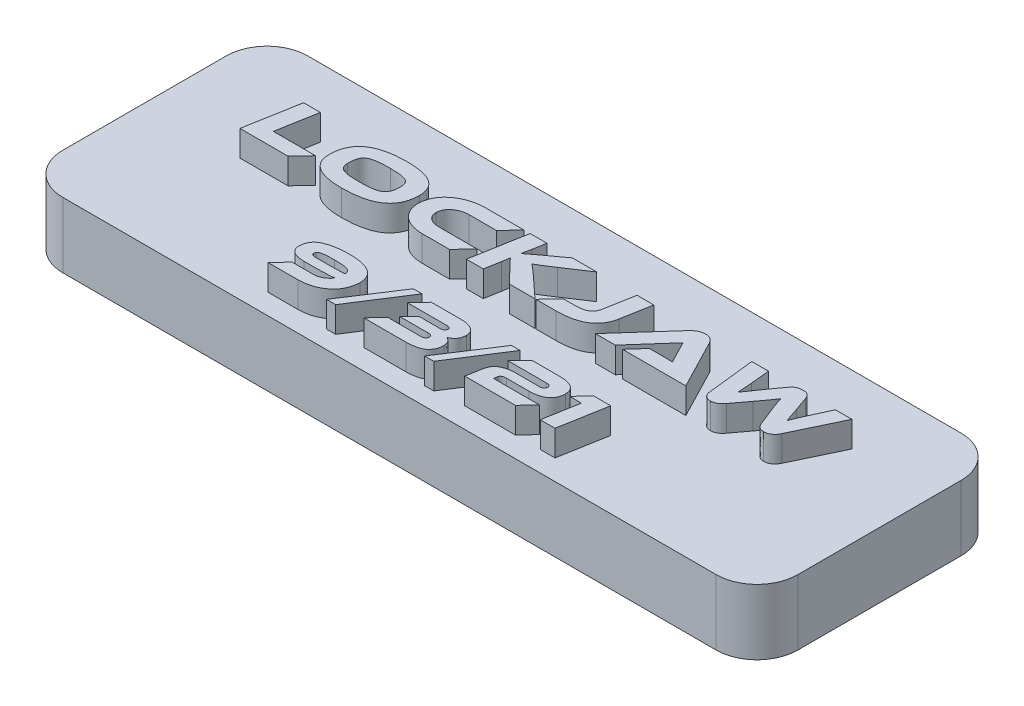
from build123d import *

# Parameters (mm, degrees)
SKETCH1_W           = 57.15
SKETCH1_H           = 19.05
BOSS_EXTRUDE1_DEPTH = 5.08
FILLET1_R           = 3.175
BOSS_EXTRUDE2_DEPTH = 2
SKETCH4_R           = 0.9
CUT_EXTRUDE1_DEPTH  = 4


with BuildPart() as part:
    # Sketch1 → Boss-Extrude1 (new body)
    with BuildSketch(Plane(origin=(0, 0, 0), x_dir=(1, 0, 0), z_dir=(0, 1, 0))):
        Rectangle(SKETCH1_W, SKETCH1_H)
    extrude(amount=BOSS_EXTRUDE1_DEPTH)

    # Fillet1
    fillet1_edges = [part.edges().sort_by_distance(p)[0] for p in [
        (-28.575, 2.54, -9.525),
        (-28.575, 2.54, 9.525),
        (28.575, 2.54, 9.525),
        (28.575, 2.54, -9.525),
    ]]
    fillet(fillet1_edges, radius=FILLET1_R)

    # Sketch3 → Boss-Extrude2 (add)
    with BuildSketch(Plane(origin=(0, 5.08, 0), x_dir=(1, 0, 0), z_dir=(0, 1, 0))):
        with BuildLine():
            add(Edge.make_bspline(
                [(18.986183794, 0.390294017), (18.99976212, 0.35659834), (19.026100294, 0.291238101), (19.081525435, 0.203566754), (19.144631038, 0.126795663), (19.217773301, 0.061464517), (19.30260435, 0.009173736), (19.399602745, -0.027898063), (19.508194542, -0.051220813), (19.584417945, -0.054206736), (19.62415657, -0.05576343)],
                knots=[0, 0, 0, 0, 0.000108788, 0.000211018, 0.000309687, 0.000406177, 0.000503855, 0.000606899, 0.00071627, 0.000835394, 0.000835394, 0.000835394, 0.000835394], degree=3))
            add(Edge.make_bspline(
                [(19.62415657, -0.05576343), (19.666042688, -0.053966236), (19.749139081, -0.050400847), (19.871269784, -0.022923383), (19.988653086, 0.022326494), (20.10037936, 0.08621565), (20.20674783, 0.166515388), (20.301522742, 0.267832701), (20.388186358, 0.385896221), (20.434086638, 0.474938977), (20.457865556, 0.521068116)],
                knots=[0, 0, 0, 0, 0.000125572, 0.000249119, 0.000373558, 0.000501686, 0.000634062, 0.000771784, 0.00091642, 0.001071894, 0.001071894, 0.001071894, 0.001071894], degree=3))
            Line((20.457865556, 0.521068116), (22.215058149, 4.208766837))
            Line((22.215058149, 4.208766837), (20.932354638, 4.208766837))
            Line((20.932354638, 4.208766837), (20.268887305, 2.747677306))
            add(Edge.make_bspline(
                [(20.268887305, 2.747677306), (20.24284878, 2.691115035), (20.192344313, 2.581406544), (20.119498413, 2.420840366), (20.053179861, 2.268156898), (19.971403478, 2.07900874), (19.879286813, 1.855843352), (19.813790966, 1.678584599), (19.782305314, 1.593371449)],
                knots=[0, 0, 0, 0, 0.000186804, 0.000362327, 0.000528939, 0.000686184, 0.000980548, 0.001253061, 0.001253061, 0.001253061, 0.001253061], degree=3))
            add(Edge.make_bspline(
                [(19.782305314, 1.593371449), (19.77106738, 1.628730463), (19.747891651, 1.701650532), (19.711147131, 1.814745435), (19.671022032, 1.934737749), (19.627147599, 2.064550408), (19.577960058, 2.208029207), (19.522457109, 2.370032374), (19.45795327, 2.551557477), (19.41350808, 2.679660987), (19.390132995, 2.747034541)],
                knots=[0, 0, 0, 0, 0.000111306, 0.000229543, 0.000356739, 0.000490873, 0.000640622, 0.000811767, 0.00100461, 0.001218549, 0.001218549, 0.001218549, 0.001218549], degree=3))
            Line((19.390132995, 2.747034541), (19.01145874, 3.807245859))
            add(Edge.make_bspline(
                [(19.01145874, 3.807245859), (18.99347067, 3.852325965), (18.959876, 3.936517944), (18.896242117, 4.046626496), (18.825696515, 4.131947336), (18.745285461, 4.191878475), (18.656078217, 4.228544866), (18.559991386, 4.254757927), (18.453739911, 4.266889771), (18.380011487, 4.266541121), (18.341597681, 4.266359469)],
                knots=[0, 0, 0, 0, 0.000145468, 0.000271678, 0.000379954, 0.000475395, 0.000569144, 0.000667601, 0.000773505, 0.000888703, 0.000888703, 0.000888703, 0.000888703], degree=3))
            add(Edge.make_bspline(
                [(18.341597681, 4.266359469), (18.303778881, 4.266605936), (18.229686331, 4.267088801), (18.120886524, 4.253253143), (18.017473425, 4.226354204), (17.916446796, 4.186729166), (17.816869629, 4.125803537), (17.716713312, 4.040430135), (17.613575981, 3.929748136), (17.548242574, 3.844050056), (17.513373623, 3.798312319)],
                knots=[0, 0, 0, 0, 0.00011337, 0.000222108, 0.00032787, 0.000433288, 0.00054648, 0.000676284, 0.000826964, 0.00099943, 0.00099943, 0.00099943, 0.00099943], degree=3))
            Line((17.513373623, 3.798312319), (16.755669807, 2.74754786))
            add(Edge.make_bspline(
                [(16.755669807, 2.74754786), (16.708968789, 2.683107943), (16.61984231, 2.560127693), (16.492980577, 2.383892073), (16.381917125, 2.222545512), (16.281756483, 2.076931266), (16.192605448, 1.942454559), (16.108851361, 1.818403356), (16.032477005, 1.701218964), (15.98309682, 1.625964326), (15.959310821, 1.589714831)],
                knots=[0, 0, 0, 0, 0.000238752, 0.000455645, 0.000651411, 0.000826366, 0.000985844, 0.001135433, 0.001275391, 0.001405461, 0.001405461, 0.001405461, 0.001405461], degree=3))
            add(Edge.make_bspline(
                [(15.959310821, 1.589714831), (15.95550415, 1.675368182), (15.947696002, 1.851058184), (15.930400577, 2.073939086), (15.916447035, 2.261979973), (15.90303314, 2.413326184), (15.890587585, 2.573966159), (15.88164471, 2.68396087), (15.877036908, 2.740635459)],
                knots=[0, 0, 0, 0, 0.000257196, 0.000527554, 0.000670584, 0.000822872, 0.00098336, 0.001153945, 0.001153945, 0.001153945, 0.001153945], degree=3))
            Line((15.877036908, 2.740635459), (15.738353229, 4.208766837))
            Line((15.738353229, 4.208766837), (14.436693509, 4.208766837))
            Line((14.436693509, 4.208766837), (14.847411382, 0.521956381))
            add(Edge.make_bspline(
                [(14.847411382, 0.521956381), (14.854071548, 0.475879894), (14.866689218, 0.388588094), (14.91073672, 0.268486973), (14.972052988, 0.166864567), (15.051783753, 0.085127629), (15.143963695, 0.021611916), (15.246993521, -0.023547257), (15.359757829, -0.05075639), (15.438087826, -0.054060316), (15.478465507, -0.05576343)],
                knots=[0, 0, 0, 0, 0.000139353, 0.000264003, 0.000380965, 0.00049281, 0.000603875, 0.000714793, 0.000828538, 0.000949553, 0.000949553, 0.000949553, 0.000949553], degree=3))
            add(Edge.make_bspline(
                [(15.478465507, -0.05576343), (15.520037297, -0.054227117), (15.601447354, -0.051218556), (15.719044365, -0.026371075), (15.829645495, 0.011033214), (15.932430796, 0.064036572), (16.028628054, 0.129041502), (16.117352912, 0.206145636), (16.201706875, 0.291606614), (16.250134159, 0.356512635), (16.274694155, 0.389429855)],
                knots=[0, 0, 0, 0, 0.000124597, 0.000243998, 0.000359058, 0.00047394, 0.000589811, 0.000706515, 0.000826116, 0.000949188, 0.000949188, 0.000949188, 0.000949188], degree=3))
            Line((16.274694155, 0.389429855), (17.16638768, 1.581524934))
            add(Edge.make_bspline(
                [(17.16638768, 1.581524934), (17.195195094, 1.619914287), (17.251436502, 1.694862747), (17.333594252, 1.80400567), (17.410456884, 1.908009798), (17.483464099, 2.005158237), (17.551176421, 2.096529307), (17.613371695, 2.182272838), (17.672133556, 2.261174582), (17.741210345, 2.35836954), (17.82141431, 2.471255316), (17.909884689, 2.599796099), (17.989842835, 2.719803389), (18.039145575, 2.797531669), (18.062780531, 2.834793382)],
                knots=[0, 0, 0, 0, 0.000143988, 0.000281111, 0.000409825, 0.000531956, 0.00064568, 0.000750998, 0.000849731, 0.000940803, 0.001108709, 0.00126516, 0.001408918, 0.001541291, 0.001541291, 0.001541291, 0.001541291], degree=3))
            add(Edge.make_bspline(
                [(18.062780531, 2.834793382), (18.073922071, 2.797272073), (18.097079181, 2.719285985), (18.135900901, 2.598434094), (18.178529085, 2.468702978), (18.22791939, 2.328207331), (18.28627708, 2.171969979), (18.352168693, 1.993762327), (18.431694754, 1.792495165), (18.488144655, 1.650343935), (18.518029517, 1.575088357)],
                knots=[0, 0, 0, 0, 0.000117418, 0.000244048, 0.000380783, 0.000527076, 0.000690779, 0.000881121, 0.001097055, 0.001339974, 0.001339974, 0.001339974, 0.001339974], degree=3))
            Line((18.518029517, 1.575088357), (18.986183794, 0.390294017))
        make_face()
        with BuildLine():
            Line((13.508655197, 0.006075914), (11.543528143, 3.800574494))
            add(Edge.make_bspline(
                [(11.543528143, 3.800574494), (11.525407199, 3.832806008), (11.489448535, 3.896765269), (11.424574846, 3.985575321), (11.347315359, 4.0630874), (11.262412447, 4.133983071), (11.164606553, 4.192399523), (11.052495404, 4.23493807), (10.926453576, 4.260058315), (10.837722643, 4.264204191), (10.791594928, 4.266359469)],
                knots=[0, 0, 0, 0, 0.000110886, 0.000220038, 0.000328642, 0.000438436, 0.000551159, 0.000668641, 0.000796469, 0.000934872, 0.000934872, 0.000934872, 0.000934872], degree=3))
            add(Edge.make_bspline(
                [(10.791594928, 4.266359469), (10.741783268, 4.264009128), (10.645052147, 4.259444915), (10.505013391, 4.230967468), (10.374734829, 4.187726952), (10.254999954, 4.126959855), (10.145318298, 4.055096369), (10.042116945, 3.977511138), (9.947810732, 3.892229282), (9.890428229, 3.830720556), (9.86189971, 3.800140628)],
                knots=[0, 0, 0, 0, 0.00014941, 0.000290146, 0.000427171, 0.000560039, 0.000691642, 0.000820174, 0.000947034, 0.001072464, 0.001072464, 0.001072464, 0.001072464], degree=3))
            Line((9.86189971, 3.800140628), (6.475901464, 0.006075914))
            Line((6.475901464, 0.006075914), (8.023991908, 0.006075914))
            Line((8.023991908, 0.006075914), (10.500936619, 2.798493231))
            Line((10.500936619, 2.798493231), (11.063304168, 1.696826253))
            add(Edge.make_bspline(
                [(11.063304168, 1.696826253), (11.089978173, 1.644325557), (11.14449442, 1.5370248), (11.213922761, 1.403208105), (11.270005855, 1.297464771), (11.31114697, 1.223921613), (11.347550811, 1.155498073), (11.372849117, 1.112747401), (11.384881256, 1.092414734)],
                knots=[0, 0, 0, 0, 0.000176664, 0.000361065, 0.000452265, 0.000535729, 0.000613867, 0.000684736, 0.000684736, 0.000684736, 0.000684736], degree=3))
            add(Edge.make_bspline(
                [(11.384881256, 1.092414734), (11.329432911, 1.095166522), (11.211273076, 1.101030553), (11.026842541, 1.103502684), (10.831823675, 1.10564963), (10.699571078, 1.105358474), (10.633446184, 1.105212899)],
                knots=[0, 0, 0, 0, 0.000166537, 0.000354888, 0.000553268, 0.00075164, 0.00075164, 0.00075164, 0.00075164], degree=3))
            Line((10.633446184, 1.105212899), (9.578401089, 1.105536066))
            Line((9.578401089, 1.105536066), (8.592678194, 0.006075914))
            Line((8.592678194, 0.006075914), (13.508655197, 0.006075914))
        make_face()
        with BuildLine():
            Line((2.896527384, 1.105536066), (1.85393586, 0.006075914))
            Line((1.85393586, 0.006075914), (3.433619987, 0.006075914))
            add(Edge.make_bspline(
                [(3.433619987, 0.006075914), (3.540603796, 0.007436861), (3.748751622, 0.01008472), (4.05203722, 0.033601879), (4.337633993, 0.070034612), (4.605136925, 0.123100908), (4.855045242, 0.190249301), (5.086842949, 0.273347313), (5.300890406, 0.371079513), (5.497144423, 0.48385062), (5.675213459, 0.612113229), (5.83541056, 0.755344205), (5.977226893, 0.913926316), (6.101380797, 1.087099416), (6.205659916, 1.276680487), (6.293868991, 1.479889032), (6.362748449, 1.698830152), (6.393462514, 1.851135315), (6.409137826, 1.928866184)],
                knots=[0, 0, 0, 0, 0.000320904, 0.000624351, 0.000912019, 0.001184167, 0.001441855, 0.001687642, 0.001922026, 0.002146874, 0.002365577, 0.002579208, 0.002790257, 0.003002581, 0.00321701, 0.003438115, 0.003666231, 0.003904002, 0.003904002, 0.003904002, 0.003904002], degree=3))
            Line((6.409137826, 1.928866184), (6.820462755, 4.208766837))
            Line((6.820462755, 4.208766837), (5.512484298, 4.208766837))
            Line((5.512484298, 4.208766837), (5.101766425, 1.929710705))
            add(Edge.make_bspline(
                [(5.101766425, 1.929710705), (5.095231607, 1.893606074), (5.082511058, 1.823325499), (5.051709765, 1.723454142), (5.014601284, 1.631221767), (4.968489875, 1.54698296), (4.913508536, 1.470828714), (4.850009523, 1.402917424), (4.778646621, 1.342591695), (4.698246485, 1.290059858), (4.606663952, 1.244899766), (4.503587515, 1.205769862), (4.387346694, 1.174394554), (4.259095052, 1.148174238), (4.118189231, 1.126841942), (3.964272012, 1.114206072), (3.797806436, 1.105451756), (3.682532606, 1.105294429), (3.622794638, 1.105212899)],
                knots=[0, 0, 0, 0, 0.000109985, 0.000214094, 0.000312895, 0.000407813, 0.000501437, 0.000593929, 0.000686046, 0.000781127, 0.000881288, 0.000991814, 0.001111359, 0.001242057, 0.001384398, 0.001538587, 0.001705167, 0.00188435, 0.00188435, 0.00188435, 0.00188435], degree=3))
            Line((3.622794638, 1.105212899), (2.896527384, 1.105536066))
        make_face()
        with BuildLine():
            add(Edge.make_bspline(
                [(0.278086897, 1.392796648), (0.222599014, 1.444148917), (0.116774505, 1.542086129), (-0.034532052, 1.681114661), (-0.171553727, 1.803755219), (-0.295233828, 1.91073157), (-0.406659478, 2.004665505), (-0.507553369, 2.087751254), (-0.59768524, 2.162340495), (-0.655654047, 2.207502793), (-0.682873478, 2.228708889)],
                knots=[0, 0, 0, 0, 0.000226812, 0.000432568, 0.000616438, 0.000778458, 0.000923128, 0.001053635, 0.001170568, 0.001274078, 0.001274078, 0.001274078, 0.001274078], degree=3))
            add(Edge.make_bspline(
                [(-0.682873478, 2.228708889), (-0.646174216, 2.248893261), (-0.5697249, 2.290939924), (-0.453204862, 2.361216069), (-0.327684242, 2.436928321), (-0.21763428, 2.505144405), (-0.124036604, 2.56592842), (-0.045394079, 2.614596148), (0.038665443, 2.668609755), (0.128233465, 2.727779939), (0.225207431, 2.789191838), (0.32764198, 2.856322237), (0.436213093, 2.927646986), (0.510990092, 2.976216726), (0.549406908, 3.001169517)],
                knots=[0, 0, 0, 0, 0.000125639, 0.000261722, 0.000408152, 0.000565422, 0.000650118, 0.000742948, 0.000842859, 0.000949858, 0.001064984, 0.001187197, 0.001317267, 0.001454695, 0.001454695, 0.001454695, 0.001454695], degree=3))
            Line((0.549406908, 3.001169517), (2.375907418, 4.208766837))
            Line((2.375907418, 4.208766837), (0.480286466, 4.208766837))
            Line((0.480286466, 4.208766837), (-0.922473039, 3.184222724))
            add(Edge.make_bspline(
                [(-0.922473039, 3.184222724), (-0.974583562, 3.145800749), (-1.074176155, 3.072369434), (-1.216449838, 2.966341556), (-1.343932519, 2.868077071), (-1.459874757, 2.78030253), (-1.563914934, 2.699934929), (-1.658107517, 2.627231809), (-1.742017243, 2.56017035), (-1.795080218, 2.518172521), (-1.820081787, 2.498384493)],
                knots=[0, 0, 0, 0, 0.000194232, 0.000371213, 0.000532293, 0.000677099, 0.000807468, 0.000926691, 0.001034053, 0.001129707, 0.001129707, 0.001129707, 0.001129707], degree=3))
            add(Edge.make_bspline(
                [(-1.820081787, 2.498384493), (-1.807635142, 2.556291112), (-1.782276644, 2.674268681), (-1.7426007, 2.854516053), (-1.702453237, 3.041935514), (-1.675607969, 3.169366069), (-1.661933043, 3.234278937)],
                knots=[0, 0, 0, 0, 0.000177687, 0.000362016, 0.000553686, 0.000752698, 0.000752698, 0.000752698, 0.000752698], degree=3))
            Line((-1.661933043, 3.234278937), (-1.491159325, 4.208766837))
            Line((-1.491159325, 4.208766837), (-2.799137782, 4.208766837))
            Line((-2.799137782, 4.208766837), (-3.551067426, 0.003655726))
            Line((-3.551067426, 0.003655726), (-2.236770233, 0.003655726))
            Line((-2.236770233, 0.003655726), (-2.021933191, 1.210511188))
            Line((-2.021933191, 1.210511188), (-1.93347088, 1.813938919))
            add(Edge.make_bspline(
                [(-1.93347088, 1.813938919), (-1.918965118, 1.795462482), (-1.887374276, 1.755224254), (-1.833571925, 1.693009619), (-1.770827678, 1.62316502), (-1.698953792, 1.544515914), (-1.614145014, 1.455892519), (-1.516383703, 1.352868269), (-1.401953851, 1.236299033), (-1.320365048, 1.153641713), (-1.277073961, 1.109783671)],
                knots=[0, 0, 0, 0, 7.0463e-05, 0.000153455, 0.000246681, 0.000352142, 0.000473063, 0.000614662, 0.000778214, 0.00096309, 0.00096309, 0.00096309, 0.00096309], degree=3))
            Line((-1.277073961, 1.109783671), (-0.195818341, 0.003655726))
            Line((-0.195818341, 0.003655726), (1.781946186, 0.003655726))
            Line((1.781946186, 0.003655726), (0.278086897, 1.392796648))
        make_face()
        with BuildLine():
            add(Edge.make_bspline(
                [(-6.798337357, 1.105536066), (-6.838058387, 1.106368572), (-6.915473869, 1.107991107), (-7.028300956, 1.120099472), (-7.134545949, 1.139341634), (-7.234957539, 1.164731953), (-7.329490449, 1.197730851), (-7.418000542, 1.237674392), (-7.500298132, 1.284870974), (-7.576103435, 1.338214411), (-7.643574673, 1.398892985), (-7.703559843, 1.463686553), (-7.754317503, 1.534061863), (-7.796801284, 1.609307897), (-7.829638278, 1.690172386), (-7.853450091, 1.775740301), (-7.868223712, 1.866215268), (-7.871183518, 1.928202108), (-7.872699324, 1.95994744)],
                knots=[0, 0, 0, 0, 0.000119146, 0.000232213, 0.000339979, 0.000442857, 0.0005426, 0.00063997, 0.000733741, 0.000826832, 0.000917476, 0.001005473, 0.001091233, 0.001177183, 0.0012641, 0.001352376, 0.001443149, 0.001538437, 0.001538437, 0.001538437, 0.001538437], degree=3))
            add(Edge.make_bspline(
                [(-7.872699324, 1.95994744), (-7.870321703, 2.00089212), (-7.865637766, 2.08155355), (-7.841878414, 2.199187811), (-7.807397548, 2.311187764), (-7.760421106, 2.41754111), (-7.700292506, 2.517456178), (-7.628868238, 2.612420697), (-7.543697211, 2.700160835), (-7.448337067, 2.782047564), (-7.343309937, 2.855559397), (-7.231827439, 2.920673089), (-7.113914533, 2.975739929), (-6.990303772, 3.021270473), (-6.860843125, 3.058247704), (-6.72533952, 3.084423964), (-6.583831529, 3.10108536), (-6.487495527, 3.104537604), (-6.438390773, 3.106297295)],
                knots=[0, 0, 0, 0, 0.000122909, 0.000242131, 0.000358943, 0.000473945, 0.00058996, 0.00070807, 0.000829622, 0.000956043, 0.00108463, 0.001213669, 0.001342898, 0.001474501, 0.001608483, 0.001746351, 0.001888089, 0.00203545, 0.00203545, 0.00203545, 0.00203545], degree=3))
            Line((-6.438390773, 3.106297295), (-4.31507391, 3.106887389))
            Line((-4.31507391, 3.106887389), (-3.278801122, 4.206347541))
            Line((-3.278801122, 4.206347541), (-6.242288544, 4.206347541))
            add(Edge.make_bspline(
                [(-6.242288544, 4.206347541), (-6.344308335, 4.202700375), (-6.54411621, 4.195557324), (-6.837332125, 4.162353327), (-7.117469231, 4.110015155), (-7.384330179, 4.036172143), (-7.638938939, 3.945267581), (-7.88006559, 3.833094278), (-8.10870688, 3.702119343), (-8.287619412, 3.576781715), (-8.423153353, 3.469194079), (-8.517230977, 3.383435035), (-8.606060518, 3.295964452), (-8.688859654, 3.205335074), (-8.764362551, 3.110727377), (-8.835548333, 3.01426649), (-8.898086777, 2.913020304), (-8.95625324, 2.809716549), (-9.007448564, 2.702914965), (-9.051291828, 2.592415367), (-9.089450236, 2.479140843), (-9.122993341, 2.363167205), (-9.147953385, 2.243547853), (-9.168651558, 2.121372678), (-9.181086219, 1.99550854), (-9.185180632, 1.910604524), (-9.187253623, 1.867617826)],
                knots=[0, 0, 0, 0, 0.000306166, 0.000599632, 0.000884344, 0.001160233, 0.001429449, 0.00169448, 0.001956971, 0.002218938, 0.002348999, 0.002475859, 0.002600617, 0.002722926, 0.00284385, 0.002963619, 0.003082322, 0.003200591, 0.003319167, 0.003437316, 0.003556997, 0.003677669, 0.003799234, 0.003923371, 0.004049262, 0.004178365, 0.004178365, 0.004178365, 0.004178365], degree=3))
            add(Edge.make_bspline(
                [(-9.187253623, 1.867617826), (-9.18425375, 1.801688472), (-9.17834879, 1.671912941), (-9.147898283, 1.482185543), (-9.099245168, 1.301387781), (-9.032438889, 1.130003576), (-8.947430611, 0.967607666), (-8.844896562, 0.814264123), (-8.722644306, 0.671011828), (-8.584413038, 0.536982875), (-8.430156534, 0.415938203), (-8.262597142, 0.308972587), (-8.081891269, 0.218224767), (-7.887661366, 0.144692398), (-7.681491487, 0.084618858), (-7.461656587, 0.042789332), (-7.229588352, 0.013380635), (-7.070165101, 0.00815489), (-6.988711836, 0.005484928)],
                knots=[0, 0, 0, 0, 0.000197872, 0.000389491, 0.000575101, 0.000758611, 0.000940158, 0.001123976, 0.001310786, 0.001504088, 0.001700684, 0.001897981, 0.00209953, 0.002306142, 0.002520237, 0.002742905, 0.002976823, 0.003221191, 0.003221191, 0.003221191, 0.003221191], degree=3))
            Line((-6.988711836, 0.005484928), (-4.864803986, 0.006075914))
            Line((-4.864803986, 0.006075914), (-3.834849935, 1.105536066))
            Line((-3.834849935, 1.105536066), (-6.798337357, 1.105536066))
        make_face()
        with BuildLine():
            add(Edge.make_bspline(
                [(-12.41441751, 4.264853435), (-12.487490224, 4.264150041), (-12.630994334, 4.262768679), (-12.842455965, 4.255304453), (-13.046731704, 4.243828802), (-13.243925852, 4.226275073), (-13.434153165, 4.204448808), (-13.61745774, 4.178135377), (-13.79375449, 4.146346882), (-13.962891887, 4.108703546), (-14.124867986, 4.066841285), (-14.27973055, 4.020018599), (-14.42794031, 3.969271115), (-14.569199404, 3.912462076), (-14.703093624, 3.850145336), (-14.830863089, 3.784672178), (-14.950912353, 3.713307743), (-15.063401162, 3.636054084), (-15.169926994, 3.555015487), (-15.268647714, 3.467997248), (-15.360501229, 3.375795294), (-15.44657254, 3.27972572), (-15.524313638, 3.176938462), (-15.596998879, 3.070861845), (-15.660439651, 2.958180712), (-15.719968361, 2.842029764), (-15.770661171, 2.71956376), (-15.814379021, 2.592115874), (-15.852316279, 2.460138961), (-15.881981709, 2.322911611), (-15.905857087, 2.180763117), (-15.923186622, 2.033740252), (-15.93351106, 1.881481624), (-15.934251986, 1.778351657), (-15.934628647, 1.725923865)],
                knots=[0, 0, 0, 0, 0.00021922, 0.000430517, 0.000634719, 0.000832939, 0.001024345, 0.001209088, 0.001388397, 0.001561619, 0.0017288, 0.001890173, 0.002046865, 0.002198625, 0.002346687, 0.00248979, 0.002629165, 0.002765325, 0.002898982, 0.003030471, 0.003159752, 0.003289265, 0.003417071, 0.003546125, 0.003674706, 0.003804712, 0.003937476, 0.004071906, 0.004208776, 0.004349179, 0.004492852, 0.004641052, 0.004793135, 0.004950393, 0.004950393, 0.004950393, 0.004950393], degree=3))
            add(Edge.make_bspline(
                [(-15.934628647, 1.725923865), (-15.932700206, 1.652651179), (-15.928958987, 1.510500548), (-15.894920117, 1.304743113), (-15.841731264, 1.113533359), (-15.766034338, 0.936607339), (-15.668481681, 0.774301847), (-15.548646873, 0.627005612), (-15.40668961, 0.495143384), (-15.243800024, 0.377875494), (-15.059361854, 0.275513814), (-14.853937578, 0.187096535), (-14.627753067, 0.111278664), (-14.379925278, 0.05083109), (-14.111479636, 0.003624777), (-13.821794326, -0.029580863), (-13.510887823, -0.049844784), (-13.296410855, -0.051940053), (-13.185765797, -0.053020966)],
                knots=[0, 0, 0, 0, 0.000219671, 0.000426167, 0.000623813, 0.000813827, 0.001001645, 0.001190103, 0.001381548, 0.00158123, 0.001790776, 0.002013083, 0.002251287, 0.002505594, 0.002777627, 0.003068474, 0.003379936, 0.003711836, 0.003711836, 0.003711836, 0.003711836], degree=3))
            add(Edge.make_bspline(
                [(-13.185765797, -0.053020966), (-13.112931131, -0.052455169), (-12.969663125, -0.051342229), (-12.758142511, -0.043724787), (-12.553852623, -0.032438481), (-12.356685132, -0.014624257), (-12.166363266, 0.006825126), (-11.983191514, 0.034388638), (-11.80685628, 0.066140884), (-11.637990359, 0.103671999), (-11.475809626, 0.145843098), (-11.320298149, 0.191939017), (-11.172255094, 0.24436261), (-11.030979389, 0.30061376), (-10.89739621, 0.363320067), (-10.769984413, 0.429548791), (-10.65023399, 0.501958418), (-10.537455839, 0.579052293), (-10.431025722, 0.660209293), (-10.331920641, 0.747143393), (-10.240711826, 0.84029394), (-10.154284341, 0.93631177), (-10.07658864, 1.03914999), (-10.003931378, 1.145233071), (-9.940198719, 1.258074334), (-9.88117739, 1.374784654), (-9.830200043, 1.497412041), (-9.786527699, 1.624884051), (-9.748592492, 1.756856749), (-9.718806446, 1.894369804), (-9.695138033, 2.036857562), (-9.677695851, 2.184166254), (-9.66739263, 2.336428379), (-9.666648778, 2.439557863), (-9.666270628, 2.491985411)],
                knots=[0, 0, 0, 0, 0.0002185, 0.000429796, 0.000634912, 0.000832221, 0.001023627, 0.001209407, 0.001387817, 0.001561039, 0.001728219, 0.001890468, 0.002047461, 0.002199222, 0.002346454, 0.00248998, 0.002629824, 0.002765984, 0.002899642, 0.003031131, 0.00316106, 0.003290573, 0.003418378, 0.003547433, 0.003676014, 0.003806837, 0.003939601, 0.004074031, 0.004210901, 0.004351303, 0.004495879, 0.004644079, 0.004796161, 0.00495342, 0.00495342, 0.00495342, 0.00495342], degree=3))
            add(Edge.make_bspline(
                [(-9.666270628, 2.491985411), (-9.66835156, 2.564930001), (-9.672404001, 2.706983534), (-9.704535356, 2.912703512), (-9.758532642, 3.104122883), (-9.834521662, 3.280748696), (-9.932475124, 3.44245971), (-10.051614119, 3.589369287), (-10.193023354, 3.721034434), (-10.356535287, 3.837071522), (-10.540568068, 3.940135668), (-10.746610644, 4.0266221), (-10.97247745, 4.102333874), (-11.220495436, 4.161421518), (-11.489113944, 4.208718585), (-11.779070302, 4.242297194), (-12.090050904, 4.261022072), (-12.304495302, 4.263336881), (-12.41441751, 4.264853435)],
                knots=[0, 0, 0, 0, 0.000218758, 0.000426013, 0.00062278, 0.000813995, 0.001001031, 0.001188203, 0.001379648, 0.001578795, 0.001788342, 0.002011126, 0.002248172, 0.002502261, 0.002775194, 0.003066041, 0.003377445, 0.003709345, 0.003709345, 0.003709345, 0.003709345], degree=3))
        make_face()
        with BuildLine():
            add(Edge.make_bspline(
                [(-12.995741268, 1.047030173), (-13.064261906, 1.04660261), (-13.19618116, 1.045779446), (-13.387040983, 1.049733712), (-13.563205392, 1.061186797), (-13.725309044, 1.075736974), (-13.872977067, 1.097737934), (-14.006303785, 1.125013299), (-14.126143516, 1.156348623), (-14.232009125, 1.194530349), (-14.325857822, 1.240026498), (-14.405753206, 1.297252332), (-14.47435919, 1.363776891), (-14.528262177, 1.441900597), (-14.571132127, 1.529303822), (-14.600956837, 1.627061382), (-14.618541942, 1.735031597), (-14.619550508, 1.81026116), (-14.620074348, 1.849334734)],
                knots=[0, 0, 0, 0, 0.000205565, 0.000395764, 0.000572537, 0.000735087, 0.000883892, 0.001020147, 0.001143219, 0.001255139, 0.001357344, 0.001455005, 0.001548736, 0.001642574, 0.001738242, 0.001839729, 0.001948086, 0.002065187, 0.002065187, 0.002065187, 0.002065187], degree=3))
            add(Edge.make_bspline(
                [(-14.620074348, 1.849334734), (-14.621722868, 1.911811071), (-14.624878718, 2.031412847), (-14.612980933, 2.203375738), (-14.588019919, 2.359667266), (-14.54917124, 2.50079582), (-14.495905949, 2.626166729), (-14.430341334, 2.737052728), (-14.348529186, 2.83042282), (-14.269323106, 2.895436203), (-14.198672358, 2.940784123), (-14.138175275, 2.971515459), (-14.071084751, 2.999666566), (-13.997819894, 3.026084681), (-13.918302258, 3.05083148), (-13.832245461, 3.072755525), (-13.739305359, 3.09131218), (-13.64021296, 3.110411596), (-13.533879375, 3.124111193), (-13.421497178, 3.137374608), (-13.302246165, 3.147018552), (-13.17668481, 3.155167115), (-13.044435416, 3.161792983), (-12.905751266, 3.165320712), (-12.76037763, 3.166041701), (-12.661345225, 3.165221911), (-12.61076256, 3.164803188)],
                knots=[0, 0, 0, 0, 0.000187411, 0.00035877, 0.00051627, 0.000661555, 0.000796714, 0.00092386, 0.001046319, 0.001167112, 0.001230003, 0.001297872, 0.001370374, 0.001448163, 0.001531436, 0.001620123, 0.001714428, 0.001815734, 0.00192278, 0.002035947, 0.002155212, 0.002281633, 0.002413427, 0.002552426, 0.00269778, 0.002849532, 0.002849532, 0.002849532, 0.002849532], degree=3))
            add(Edge.make_bspline(
                [(-12.61076256, 3.164803188), (-12.54189731, 3.165086646), (-12.408719464, 3.165634822), (-12.216296995, 3.161832074), (-12.038604406, 3.150341942), (-11.875309443, 3.135653139), (-11.726660115, 3.114010286), (-11.592525781, 3.086275793), (-11.472491776, 3.055550786), (-11.366871648, 3.01670025), (-11.27332312, 2.971781209), (-11.194078698, 2.913989507), (-11.125752645, 2.847457656), (-11.070555236, 2.770130915), (-11.028908983, 2.682069422), (-11.000152171, 2.584313015), (-10.982294275, 2.476491904), (-10.981327212, 2.401253582), (-10.980824928, 2.362175459)],
                knots=[0, 0, 0, 0, 0.000206599, 0.00039954, 0.000577225, 0.000740685, 0.000891298, 0.001027553, 0.001151508, 0.001262569, 0.001364775, 0.001461693, 0.001555424, 0.00164979, 0.00174506, 0.001846279, 0.001954636, 0.002071737, 0.002071737, 0.002071737, 0.002071737], degree=3))
            add(Edge.make_bspline(
                [(-10.980824928, 2.362175459), (-10.979202554, 2.300007823), (-10.97609742, 2.181022384), (-10.987669119, 2.009565903), (-11.013895913, 1.85401663), (-11.052829077, 1.713235889), (-11.105723704, 1.587793863), (-11.172491868, 1.477427264), (-11.254520861, 1.383606431), (-11.333987434, 1.317707612), (-11.405725841, 1.272767382), (-11.466570865, 1.241979786), (-11.533240443, 1.212524455), (-11.607025104, 1.186264377), (-11.686891096, 1.161664348), (-11.773634432, 1.139884782), (-11.866551131, 1.119635522), (-11.966388344, 1.102726509), (-12.072390278, 1.086938186), (-12.185207526, 1.074209563), (-12.304444032, 1.064550242), (-12.430305563, 1.056272217), (-12.56255975, 1.049750773), (-12.701546778, 1.046182113), (-12.846920811, 1.045470465), (-12.945953161, 1.046288949), (-12.995741268, 1.047030173)],
                knots=[0, 0, 0, 0, 0.000186496, 0.000356944, 0.000514595, 0.000659, 0.000794159, 0.000921781, 0.00104424, 0.00116632, 0.001229983, 0.001297853, 0.001370716, 0.001448505, 0.001532652, 0.001621339, 0.001716727, 0.001817873, 0.001925047, 0.002038214, 0.00215839, 0.002283899, 0.002416606, 0.002555606, 0.002700959, 0.002852711, 0.002852711, 0.002852711, 0.002852711], degree=3))
        make_face(mode=Mode.SUBTRACT)
        Polygon((-19.663800884, 1.105536066), (-19.107752071, 4.208766837), (-20.409411791, 4.208766837), (-21.161341436, 0.006075914), (-17.42696816, 0.006075914), (-16.384376636, 1.105536066), align=None)
        Polygon((9.710846154, -5.218973535), (10.612055948, -5.218973535), (10.131042132, -7.93430124), (11.275523281, -7.93430124), (11.93346172, -4.256945902), (10.578882582, -4.256945902), align=None)
        with BuildLine():
            Line((4.894237041, -5.218973535), (7.885368935, -5.218973535))
            add(Edge.make_bspline(
                [(7.885368935, -5.218973535), (7.913069849, -5.218922741), (7.964916224, -5.218827674), (8.037645227, -5.225918073), (8.099169268, -5.242216387), (8.150999805, -5.26353583), (8.191093194, -5.294908436), (8.219407194, -5.334273792), (8.236959171, -5.381008794), (8.238183871, -5.4147712), (8.238818237, -5.432259348)],
                knots=[0, 0, 0, 0, 8.3099e-05, 0.000155531, 0.000218392, 0.000273538, 0.000322508, 0.000368908, 0.000417497, 0.000469711, 0.000469711, 0.000469711, 0.000469711], degree=3))
            add(Edge.make_bspline(
                [(8.238818237, -5.432259348), (8.238178443, -5.458018948), (8.236968839, -5.506720508), (8.216406453, -5.573936821), (8.183120077, -5.630194031), (8.133906454, -5.673414306), (8.070375355, -5.704561408), (7.992641188, -5.726311626), (7.899516029, -5.738498194), (7.832514384, -5.73961472), (7.796481685, -5.740215175)],
                knots=[0, 0, 0, 0, 7.6993e-05, 0.000145564, 0.000208395, 0.000270703, 0.000339032, 0.00041902, 0.000511893, 0.000619952, 0.000619952, 0.000619952, 0.000619952], degree=3))
            Line((7.796481685, -5.740215175), (6.038718191, -5.739416071))
            add(Edge.make_bspline(
                [(6.038718191, -5.739416071), (5.983116035, -5.740560639), (5.874862873, -5.742789025), (5.716867546, -5.753609346), (5.568148187, -5.772857955), (5.428525319, -5.798779792), (5.298262121, -5.833149331), (5.177183268, -5.875619954), (5.064915888, -5.92500466), (4.961714021, -5.98174212), (4.868244824, -6.047028209), (4.783719331, -6.120143527), (4.708318722, -6.201107035), (4.6423177, -6.289606037), (4.585936126, -6.385733808), (4.538840371, -6.489539314), (4.499893008, -6.600822081), (4.482571332, -6.678800473), (4.473758291, -6.718474855)],
                knots=[0, 0, 0, 0, 0.000166829, 0.000324804, 0.000474816, 0.000616477, 0.000750546, 0.000878553, 0.001001026, 0.001118108, 0.001231277, 0.001342418, 0.001452782, 0.001562526, 0.00167296, 0.001786425, 0.001904052, 0.002025887, 0.002025887, 0.002025887, 0.002025887], degree=3))
            Line((4.473758291, -6.718474855), (4.25841418, -7.932183575))
            Line((4.25841418, -7.932183575), (8.194987024, -7.932183575))
            Line((8.194987024, -7.932183575), (9.101725713, -6.970155942))
            Line((9.101725713, -6.970155942), (5.530059902, -6.970155942))
            Line((5.530059902, -6.970155942), (5.579819952, -6.707239748))
            add(Edge.make_bspline(
                [(5.579819952, -6.707239748), (5.583597476, -6.686112106), (5.590920233, -6.645156023), (5.619631586, -6.590591717), (5.657992279, -6.543848716), (5.70933161, -6.508043577), (5.770407077, -6.47963759), (5.842724697, -6.461031101), (5.925788118, -6.450993538), (5.984711628, -6.450679637), (6.015937083, -6.450513291)],
                knots=[0, 0, 0, 0, 6.4036e-05, 0.000124134, 0.000182613, 0.000243892, 0.000310094, 0.000383827, 0.000466868, 0.000560486, 0.000560486, 0.000560486, 0.000560486], degree=3))
            Line((6.015937083, -6.450513291), (7.774791046, -6.449714187))
            add(Edge.make_bspline(
                [(7.774791046, -6.449714187), (7.840472071, -6.448593152), (7.967806512, -6.446419826), (8.151704361, -6.426694059), (8.323120971, -6.400940141), (8.480967857, -6.361961645), (8.626721851, -6.315052912), (8.758063106, -6.255202462), (8.877536221, -6.187512089), (8.982248661, -6.107690588), (9.074831853, -6.020066732), (9.155288214, -5.925525662), (9.223067099, -5.823724541), (9.278819901, -5.715194429), (9.32095587, -5.599220599), (9.351651306, -5.476792913), (9.369306651, -5.347458364), (9.371259605, -5.259004345), (9.372255658, -5.21389067)],
                knots=[0, 0, 0, 0, 0.00019697, 0.000381861, 0.000554393, 0.000716581, 0.000869107, 0.001013024, 0.00114885, 0.001280192, 0.001406932, 0.001530654, 0.001651783, 0.001773055, 0.001895792, 0.002021116, 0.002151095, 0.002286391, 0.002286391, 0.002286391, 0.002286391], degree=3))
            add(Edge.make_bspline(
                [(9.372255658, -5.21389067), (9.371803203, -5.1780961), (9.370917459, -5.108023129), (9.354707611, -5.005989197), (9.330715539, -4.909275966), (9.294180836, -4.818686266), (9.246546483, -4.734234215), (9.188467441, -4.655338408), (9.120099814, -4.582231577), (9.040805374, -4.515185386), (8.949982457, -4.455053695), (8.846403837, -4.402688892), (8.730170716, -4.359688685), (8.601983237, -4.322394884), (8.461180228, -4.294289614), (8.307833182, -4.27367202), (8.141966652, -4.26108405), (8.027137036, -4.258543735), (7.967657132, -4.257227893)],
                knots=[0, 0, 0, 0, 0.000107259, 0.000209975, 0.000309113, 0.00040566, 0.000501999, 0.00059927, 0.000698874, 0.0008016, 0.000910084, 0.001024914, 0.001148961, 0.001281358, 0.001425053, 0.00157924, 0.00174531, 0.001923772, 0.001923772, 0.001923772, 0.001923772], degree=3))
            Line((7.967657132, -4.257227893), (5.80097573, -4.256945902))
            Line((5.80097573, -4.256945902), (4.894237041, -5.218973535))
        make_face()
        Polygon((4.0084266, -4.05005839), (1.343499478, -8.139071868), (2.056726861, -8.139071868), (4.682951722, -4.05005839), align=None)
        with BuildLine():
            Line((-3.584918597, -7.932183575), (-0.32839977, -7.932183575))
            add(Edge.make_bspline(
                [(-0.32839977, -7.932183575), (-0.286383473, -7.93123587), (-0.204058777, -7.929378983), (-0.083062886, -7.923037277), (0.032654988, -7.913254577), (0.143430248, -7.901623973), (0.248731668, -7.886187648), (0.348917171, -7.869042189), (0.44351634, -7.847894486), (0.532746284, -7.825100472), (0.616861791, -7.799290342), (0.695389706, -7.77082736), (0.768980747, -7.739583859), (0.836820825, -7.704897995), (0.900347943, -7.668886302), (0.957258697, -7.627851966), (1.010281081, -7.586408565), (1.071505268, -7.526093275), (1.139716862, -7.447939794), (1.210293914, -7.349103621), (1.270061869, -7.247349748), (1.317566646, -7.141977162), (1.353040099, -7.033365496), (1.376318121, -6.921258258), (1.387751117, -6.805632209), (1.386190462, -6.727558847), (1.38540128, -6.688079215)],
                knots=[0, 0, 0, 0, 0.000126077, 0.000247029, 0.000363409, 0.000474443, 0.000581116, 0.000682639, 0.000779289, 0.000871831, 0.000958868, 0.001043129, 0.001122322, 0.001198517, 0.00127164, 0.001341101, 0.001408809, 0.001473297, 0.001598583, 0.001719557, 0.001837129, 0.001952051, 0.002065626, 0.002179204, 0.002294931, 0.002413314, 0.002413314, 0.002413314, 0.002413314], degree=3))
            add(Edge.make_bspline(
                [(1.38540128, -6.688079215), (1.383378638, -6.645034748), (1.379486094, -6.562196351), (1.354941173, -6.444259027), (1.313727655, -6.339492999), (1.258278681, -6.247902175), (1.189498154, -6.171048672), (1.111679574, -6.10652163), (1.02360285, -6.055707807), (0.958996435, -6.034777591), (0.926267138, -6.024174444)],
                knots=[0, 0, 0, 0, 0.000129139, 0.000248525, 0.000359482, 0.000465388, 0.000567951, 0.000667397, 0.000767703, 0.000870689, 0.000870689, 0.000870689, 0.000870689], degree=3))
            add(Edge.make_bspline(
                [(0.926267138, -6.024174444), (0.967597793, -6.009960653), (1.050881944, -5.981318874), (1.167342108, -5.914739414), (1.277069116, -5.831227741), (1.361893804, -5.748532962), (1.423284875, -5.672798575), (1.46461194, -5.610121102), (1.498699672, -5.541280496), (1.528345607, -5.468161351), (1.551857412, -5.389726388), (1.567910247, -5.306040388), (1.580621101, -5.217443624), (1.583235735, -5.156345524), (1.584572711, -5.125103406)],
                knots=[0, 0, 0, 0, 0.000130881, 0.000263734, 0.000400196, 0.000543864, 0.000617818, 0.000692362, 0.000768557, 0.000847875, 0.000928857, 0.001013724, 0.001103318, 0.001197072, 0.001197072, 0.001197072, 0.001197072], degree=3))
            add(Edge.make_bspline(
                [(1.584572711, -5.125103406), (1.583232965, -5.090373417), (1.580629974, -5.022896543), (1.563583248, -4.924759117), (1.53551598, -4.833556952), (1.497778687, -4.74840209), (1.449247298, -4.670190772), (1.390585569, -4.598383368), (1.320535253, -4.534139714), (1.241382205, -4.475547046), (1.152050841, -4.424861588), (1.054892809, -4.380021469), (0.949596513, -4.341403135), (0.83580636, -4.310565354), (0.713906689, -4.286619559), (0.583737532, -4.270262105), (0.445441228, -4.259706834), (0.350369752, -4.258068877), (0.301556745, -4.257227893)],
                knots=[0, 0, 0, 0, 0.000104182, 0.000202415, 0.000297803, 0.000389821, 0.000481053, 0.000573127, 0.000667078, 0.000765468, 0.000867956, 0.000974605, 0.001086203, 0.001203992, 0.00132792, 0.001458586, 0.001597356, 0.00174379, 0.00174379, 0.00174379, 0.00174379], degree=3))
            Line((0.301556745, -4.257227893), (-2.014712575, -4.256945902))
            Line((-2.014712575, -4.256945902), (-2.921451264, -5.218973535))
            Line((-2.921451264, -5.218973535), (0.174729625, -5.218973535))
            add(Edge.make_bspline(
                [(0.174729625, -5.218973535), (0.192782503, -5.219195663), (0.227868319, -5.219627369), (0.278607316, -5.228283394), (0.326267388, -5.240429742), (0.369072365, -5.259411957), (0.40660968, -5.284007636), (0.434912262, -5.317589756), (0.451051155, -5.359825366), (0.45425199, -5.390000635), (0.455934601, -5.405863134)],
                knots=[0, 0, 0, 0, 5.4079e-05, 0.000105103, 0.000154, 0.000201268, 0.000244977, 0.000287582, 0.000330657, 0.000378396, 0.000378396, 0.000378396, 0.000378396], degree=3))
            add(Edge.make_bspline(
                [(0.455934601, -5.405863134), (0.454096284, -5.430312402), (0.450621522, -5.476526055), (0.428791972, -5.540002066), (0.393505772, -5.592061965), (0.344494627, -5.629761186), (0.288180517, -5.655905201), (0.226965097, -5.675731181), (0.160648348, -5.686777079), (0.114689202, -5.68773353), (0.09118692, -5.688222633)],
                knots=[0, 0, 0, 0, 7.3319e-05, 0.000138587, 0.00019894, 0.000259277, 0.000321525, 0.000384513, 0.000451841, 0.000522304, 0.000522304, 0.000522304, 0.000522304], degree=3))
            Line((0.09118692, -5.688222633), (-1.550285442, -5.688222633))
            Line((-1.550285442, -5.688222633), (-2.285628403, -6.449714187))
            Line((-2.285628403, -6.449714187), (-0.068541731, -6.449714187))
            add(Edge.make_bspline(
                [(-0.068541731, -6.449714187), (-0.042983599, -6.450477347), (0.004719616, -6.451901753), (0.071259449, -6.462295485), (0.12767871, -6.478314945), (0.174342181, -6.50173535), (0.210582503, -6.532597577), (0.236576106, -6.570559095), (0.250347166, -6.615980043), (0.25140557, -6.647995141), (0.251963859, -6.664882542)],
                knots=[0, 0, 0, 0, 7.6645e-05, 0.000143055, 0.000201512, 0.000251956, 0.000298459, 0.000342829, 0.000388113, 0.000438664, 0.000438664, 0.000438664, 0.000438664], degree=3))
            add(Edge.make_bspline(
                [(0.251963859, -6.664882542), (0.251487855, -6.688229704), (0.250578437, -6.732835091), (0.231350974, -6.795336816), (0.199782738, -6.849505947), (0.152563101, -6.892453142), (0.093910868, -6.927804649), (0.020929858, -6.950272738), (-0.063791542, -6.966892139), (-0.124947739, -6.969204801), (-0.157577397, -6.970438714)],
                knots=[0, 0, 0, 0, 6.9755e-05, 0.000133269, 0.000193903, 0.000255577, 0.000322658, 0.000397783, 0.000483281, 0.000581077, 0.000581077, 0.000581077, 0.000581077], degree=3))
            Line((-0.157577397, -6.970438714), (-2.689237697, -6.970155942))
            Line((-2.689237697, -6.970155942), (-3.584918597, -7.932183575))
        make_face()
        Polygon((-3.619279294, -4.05005839), (-6.284206416, -8.139071868), (-5.570979032, -8.139071868), (-2.944754172, -4.05005839), align=None)
        with BuildLine():
            Line((-10.1341784, -6.970155942), (-11.029434361, -7.932183575))
            Line((-11.029434361, -7.932183575), (-8.711256721, -7.932183575))
            add(Edge.make_bspline(
                [(-8.711256721, -7.932183575), (-8.621410464, -7.929777147), (-8.444840762, -7.92504793), (-8.185829898, -7.89377972), (-7.937790567, -7.845456505), (-7.701302252, -7.778119368), (-7.476029452, -7.693257531), (-7.262352982, -7.589683886), (-7.060269533, -7.467776465), (-6.902088472, -7.351552012), (-6.78285318, -7.251102183), (-6.699503392, -7.171271707), (-6.620978372, -7.089073015), (-6.547763185, -7.003301544), (-6.481023729, -6.913691428), (-6.418689744, -6.821436558), (-6.363128272, -6.725101624), (-6.311473615, -6.626227548), (-6.2668142, -6.523415525), (-6.22764326, -6.417304195), (-6.193003164, -6.308297587), (-6.165399273, -6.195383605), (-6.141648073, -6.079711014), (-6.125602368, -5.960192069), (-6.112964463, -5.837767761), (-6.109616535, -5.75491021), (-6.107923889, -5.713019076)],
                knots=[0, 0, 0, 0, 0.000269512, 0.000529657, 0.000781592, 0.001026938, 0.001266417, 0.001502887, 0.001738287, 0.001973466, 0.00209094, 0.002205793, 0.002319514, 0.002431869, 0.002543853, 0.002654555, 0.002765679, 0.002877297, 0.002989052, 0.003101677, 0.003216532, 0.003331962, 0.003450243, 0.003570604, 0.003693573, 0.003819318, 0.003819318, 0.003819318, 0.003819318], degree=3))
            add(Edge.make_bspline(
                [(-6.107923889, -5.713019076), (-6.110049009, -5.652117472), (-6.1141828, -5.533651456), (-6.142571426, -5.361744864), (-6.188860208, -5.20161806), (-6.253081491, -5.05300733), (-6.335699155, -4.916595218), (-6.435227494, -4.79126316), (-6.554928255, -4.67984859), (-6.690382543, -4.578328397), (-6.845085026, -4.490460709), (-7.016819167, -4.413762538), (-7.206498998, -4.349318484), (-7.413562974, -4.296844754), (-7.638423939, -4.256528236), (-7.880933649, -4.227593809), (-8.141195036, -4.208531898), (-8.32063751, -4.206884801), (-8.413193225, -4.206035236)],
                knots=[0, 0, 0, 0, 0.00018267, 0.00035533, 0.000521131, 0.000681619, 0.000839513, 0.000998287, 0.001160113, 0.00132873, 0.001505033, 0.001692644, 0.001892226, 0.002105242, 0.002332894, 0.00257706, 0.002837673, 0.00311529, 0.00311529, 0.00311529, 0.00311529], degree=3))
            add(Edge.make_bspline(
                [(-8.413193225, -4.206035236), (-8.496392079, -4.205592276), (-8.659930908, -4.204721577), (-8.90116953, -4.215578286), (-9.133990357, -4.234927868), (-9.358416509, -4.265660573), (-9.574563808, -4.305110003), (-9.78198535, -4.355643498), (-9.980905558, -4.415783415), (-10.140350074, -4.473503284), (-10.262210292, -4.525130752), (-10.346676637, -4.569635858), (-10.426684314, -4.616422557), (-10.499891343, -4.668834502), (-10.56877088, -4.723868288), (-10.630979169, -4.784450305), (-10.688946934, -4.847987079), (-10.740311989, -4.916899938), (-10.786693576, -4.989145242), (-10.826874435, -5.066161285), (-10.862116829, -5.146801308), (-10.891681935, -5.2318633), (-10.915685955, -5.32088445), (-10.933951484, -5.41389817), (-10.946975097, -5.510872203), (-10.950855436, -5.57700115), (-10.952828943, -5.610633762)],
                knots=[0, 0, 0, 0, 0.000249565, 0.000490555, 0.000724179, 0.0009502, 0.001169841, 0.001383052, 0.001590297, 0.00179299, 0.001891509, 0.001987031, 0.002079216, 0.002169319, 0.002256891, 0.002343445, 0.002429536, 0.002514644, 0.002600961, 0.002686833, 0.002774954, 0.002864759, 0.002956732, 0.003051325, 0.003148954, 0.003249996, 0.003249996, 0.003249996, 0.003249996], degree=3))
            add(Edge.make_bspline(
                [(-10.952828943, -5.610633762), (-10.951394089, -5.643753438), (-10.948588592, -5.708510641), (-10.932707199, -5.802650158), (-10.905719784, -5.890402518), (-10.870916567, -5.972873051), (-10.824799185, -6.048807605), (-10.768234836, -6.117637999), (-10.702623742, -6.18094304), (-10.627159241, -6.237416652), (-10.543193181, -6.287658407), (-10.451167228, -6.330947125), (-10.351560835, -6.367615523), (-10.24412204, -6.398128227), (-10.128746954, -6.420818141), (-10.005888135, -6.437537883), (-9.875561277, -6.448004733), (-9.786082694, -6.449663014), (-9.74020288, -6.450513291)],
                knots=[0, 0, 0, 0, 9.9392e-05, 0.000194336, 0.000285432, 0.000374287, 0.00046222, 0.000550917, 0.000640864, 0.000735091, 0.000833037, 0.000933937, 0.001039728, 0.001151139, 0.001268635, 0.001392165, 0.00152296, 0.001660599, 0.001660599, 0.001660599, 0.001660599], degree=3))
            add(Edge.make_bspline(
                [(-9.74020288, -6.450513291), (-9.686610375, -6.450588766), (-9.581824333, -6.450736339), (-9.428247631, -6.449683936), (-9.281335315, -6.448934551), (-9.141355104, -6.448155746), (-9.008041814, -6.447263447), (-8.881654136, -6.446777451), (-8.761943212, -6.444902162), (-8.648891307, -6.443402764), (-8.542776033, -6.441665317), (-8.443574534, -6.440519694), (-8.351081454, -6.437415789), (-8.265465437, -6.436504009), (-8.186556008, -6.433778787), (-8.114569717, -6.43134803), (-8.04921299, -6.429349577), (-7.9724726, -6.424605461), (-7.885214198, -6.420771207), (-7.787945774, -6.413793257), (-7.699346421, -6.408049685), (-7.619472503, -6.400065169), (-7.548086835, -6.394706302), (-7.485795565, -6.386176476), (-7.432134436, -6.378534723), (-7.399456472, -6.372485855), (-7.384540773, -6.369724879)],
                knots=[0, 0, 0, 0, 0.000160777, 0.000314357, 0.000460738, 0.00060152, 0.000734304, 0.000860688, 0.000980681, 0.001093477, 0.001199873, 0.001299072, 0.00139109, 0.001477493, 0.001555918, 0.001627948, 0.001693582, 0.001752061, 0.001858593, 0.001955591, 0.002044608, 0.00212492, 0.002196397, 0.002259299, 0.002313485, 0.002358987, 0.002358987, 0.002358987, 0.002358987], degree=3))
            add(Edge.make_bspline(
                [(-7.384540773, -6.369724879), (-7.414261829, -6.410755391), (-7.474107101, -6.493372984), (-7.581801202, -6.604032197), (-7.701725296, -6.70577684), (-7.812268259, -6.780745718), (-7.907224301, -6.833676621), (-7.982024054, -6.868964979), (-8.059264509, -6.899761591), (-8.140156427, -6.923136897), (-8.223232609, -6.943784293), (-8.309950021, -6.957621584), (-8.39936696, -6.967749518), (-8.460091072, -6.969535864), (-8.490782095, -6.970438714)],
                knots=[0, 0, 0, 0, 0.000151822, 0.000305704, 0.000461788, 0.000623076, 0.000705429, 0.000787724, 0.000871054, 0.000954565, 0.001040123, 0.001127702, 0.001217802, 0.001309875, 0.001309875, 0.001309875, 0.001309875], degree=3))
            Line((-8.490782095, -6.970438714), (-10.1341784, -6.970155942))
        make_face()
        with BuildLine():
            add(Edge.make_bspline(
                [(-9.524004204, -5.739416071), (-9.552389222, -5.739333167), (-9.605577937, -5.739177819), (-9.679328265, -5.728388524), (-9.742215669, -5.712937853), (-9.794138814, -5.691097621), (-9.835258049, -5.66209877), (-9.863472789, -5.625127048), (-9.881605078, -5.582069955), (-9.882775775, -5.550830586), (-9.883382343, -5.534644662)],
                knots=[0, 0, 0, 0, 8.5051e-05, 0.000159372, 0.000223007, 0.000278884, 0.00032752, 0.000371998, 0.000416856, 0.000465088, 0.000465088, 0.000465088, 0.000465088], degree=3))
            add(Edge.make_bspline(
                [(-9.883382343, -5.534644662), (-9.884584629, -5.520492659), (-9.886938555, -5.492784798), (-9.87899188, -5.451904192), (-9.863711991, -5.413284736), (-9.838797658, -5.377865243), (-9.806510655, -5.344746874), (-9.765245751, -5.315137149), (-9.716617334, -5.287204256), (-9.658133632, -5.262102266), (-9.587638688, -5.239181686), (-9.501499799, -5.220969825), (-9.399557666, -5.204302076), (-9.281286075, -5.19102051), (-9.14681825, -5.180808804), (-8.995827086, -5.174134861), (-8.828634472, -5.169033665), (-8.711821634, -5.168550026), (-8.650759149, -5.16829721)],
                knots=[0, 0, 0, 0, 4.2424e-05, 8.3061e-05, 0.000123611, 0.000166209, 0.000212026, 0.00026178, 0.000318034, 0.000380003, 0.000452348, 0.000540062, 0.000643816, 0.000762183, 0.000896965, 0.001048315, 0.00121556, 0.00139874, 0.00139874, 0.00139874, 0.00139874], degree=3))
            add(Edge.make_bspline(
                [(-8.650759149, -5.16829721), (-8.59823262, -5.167787601), (-8.496106704, -5.166796781), (-8.347561906, -5.169363834), (-8.20828181, -5.174373781), (-8.07845543, -5.184530804), (-7.95775916, -5.195834798), (-7.846376531, -5.211544935), (-7.744637012, -5.232098586), (-7.651424063, -5.253456427), (-7.567803304, -5.280784321), (-7.49431335, -5.316195779), (-7.431671038, -5.359607715), (-7.378102803, -5.409671023), (-7.336361787, -5.468468051), (-7.303507134, -5.534032814), (-7.283060297, -5.607713922), (-7.277178334, -5.659314386), (-7.274156606, -5.685822977)],
                knots=[0, 0, 0, 0, 0.000157579, 0.000306377, 0.00044567, 0.000575606, 0.000696984, 0.000809313, 0.000912848, 0.001008299, 0.001096072, 0.001176204, 0.001252088, 0.00132394, 0.001394981, 0.001467241, 0.001542944, 0.00162292, 0.00162292, 0.00162292, 0.00162292], degree=3))
            add(Edge.make_bspline(
                [(-7.274156606, -5.685822977), (-7.291747311, -5.688016622), (-7.329294776, -5.692698971), (-7.38905186, -5.698817251), (-7.455626655, -5.705774202), (-7.529053723, -5.709867374), (-7.609029479, -5.714809123), (-7.695666031, -5.719762177), (-7.788996792, -5.723691176), (-7.892196397, -5.726773296), (-8.011366255, -5.730355113), (-8.152963268, -5.73231403), (-8.319870653, -5.734779827), (-8.511840146, -5.737306699), (-8.729145621, -5.738848781), (-8.97177991, -5.739352636), (-9.239740538, -5.740463735), (-9.42664772, -5.740300435), (-9.524004204, -5.739416071)],
                knots=[0, 0, 0, 0, 5.3179e-05, 0.000113511, 0.000180209, 0.000253954, 0.000334087, 0.000420608, 0.00051428, 0.000614317, 0.000730344, 0.000871944, 0.001039137, 0.001231125, 0.0014479, 0.001691066, 0.001959029, 0.002251787, 0.002251787, 0.002251787, 0.002251787], degree=3))
        make_face(mode=Mode.SUBTRACT)
    extrude(amount=BOSS_EXTRUDE2_DEPTH)

    # Sketch4 → Cut-Extrude1 (cut)
    with BuildSketch(Plane.XZ):
        with Locations((-25.4, 0)):
            Circle(SKETCH4_R)
        with Locations((25.4, 0)):
            Circle(SKETCH4_R)
    extrude(amount=-CUT_EXTRUDE1_DEPTH, mode=Mode.SUBTRACT)


solid = part.part
